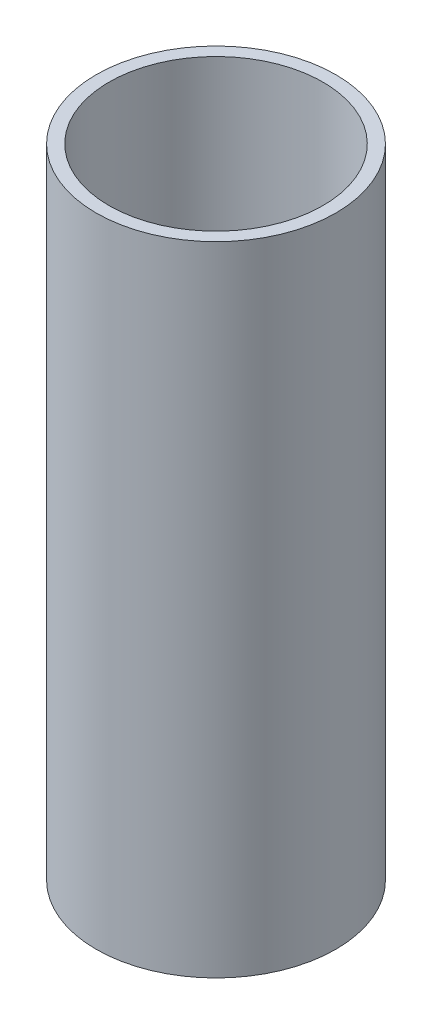
from build123d import *

# Parameters (mm, degrees)
SKETCH1_R           = 14
SKETCH1_R_2         = 12.5
BOSS_EXTRUDE1_DEPTH = 74.498
SCALE1_SCALE        = 0.75


with BuildPart() as part:
    # Sketch1 → Boss-Extrude1 (new body)
    with BuildSketch(Plane(origin=(0, 0, 0), x_dir=(1, 0, 0), z_dir=(0, 1, 0))):
        Circle(SKETCH1_R)
        Circle(SKETCH1_R_2, mode=Mode.SUBTRACT)
    extrude(amount=BOSS_EXTRUDE1_DEPTH)


with BuildPart() as part_1:
    # Scale1: scaled about (0, 37.249, 0)
    add(part.part.scale(SCALE1_SCALE).moved(Location((0, 9.31225, 0))))


solid = part_1.part
